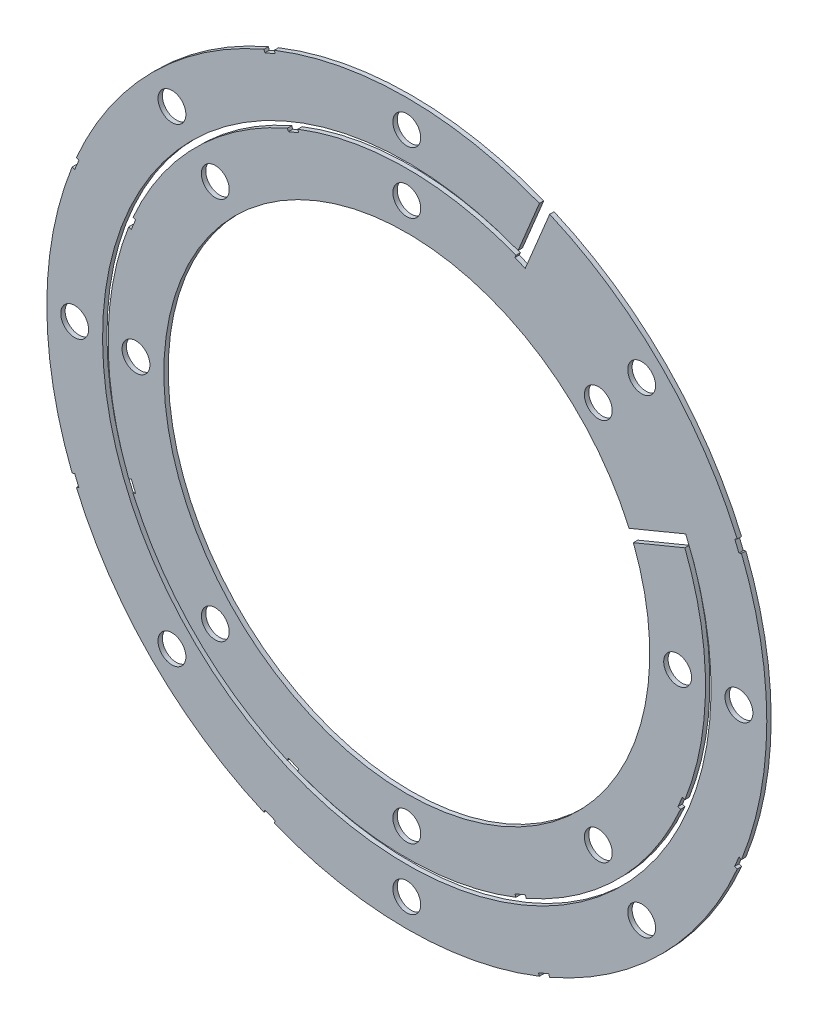
from build123d import *

# Parameters (mm, degrees)
BOSS_EXTRUDE1_DEPTH = 1
SKETCH2_R           = 3.17500001
SKETCH2_R_2         = 3.175
CUT_EXTRUDE1_DEPTH  = 2
CUT_EXTRUDE2_DEPTH  = 2


with BuildPart() as part:
    # Sketch1 → Boss-Extrude1 (new body)
    with BuildSketch(Plane.XY):
        with BuildLine():
            Line((25.358256565, 64.538916848), (30.219025255, 76.273850543))
            ThreePointArc((30.219025255, 76.273850543), (-31.396114158, -75.796924606), (32.565679267, 75.301834625))
            Line((32.565679267, 75.301834625), (27.218819563, 62.393373411))
            ThreePointArc((27.218819563, 62.393373411), (-49.023820587, -47.227769363), (63.365389329, 24.872165551))
            Line((63.365389329, 24.872165551), (51.629608078, 20.011045792))
            ThreePointArc((51.629608078, 20.011045792), (-51.157057474, -21.189947017), (50.65759216, 22.357699804))
            Line((50.65759216, 22.357699804), (63.56690093, 27.704910578))
            ThreePointArc((63.56690093, 27.704910578), (-48.125948441, -49.921999666), (25.358256565, 64.538916848))
        make_face()
    extrude(amount=BOSS_EXTRUDE1_DEPTH)

    # Sketch2 → Cut-Extrude1 (cut, through all)
    with BuildSketch(Plane.XY.offset(1)):
        with Locations((61.722, 0)):
            Circle(SKETCH2_R)
        with Locations((75.692, 0)):
            Circle(SKETCH2_R_2)
        with Locations((53.522326482, -53.522326482)):
            Circle(SKETCH2_R_2)
        with Locations((43.644044748, -43.644044748)):
            Circle(SKETCH2_R)
        with Locations((0, -75.692)):
            Circle(SKETCH2_R_2)
        with Locations((0, -61.722)):
            Circle(SKETCH2_R)
        with Locations((-53.522326482, -53.522326482)):
            Circle(SKETCH2_R_2)
        with Locations((-43.644044748, -43.644044748)):
            Circle(SKETCH2_R)
        with Locations((-75.692, 0)):
            Circle(SKETCH2_R_2)
        with Locations((-61.722, 0)):
            Circle(SKETCH2_R)
        with Locations((-53.522326482, 53.522326482)):
            Circle(SKETCH2_R_2)
        with Locations((-43.644044748, 43.644044748)):
            Circle(SKETCH2_R)
        with Locations((0, 75.692)):
            Circle(SKETCH2_R_2)
        with Locations((0, 61.722)):
            Circle(SKETCH2_R)
        with Locations((53.522326482, 53.522326482)):
            Circle(SKETCH2_R_2)
        with Locations((43.644044748, 43.644044748)):
            Circle(SKETCH2_R)
    extrude(amount=-CUT_EXTRUDE1_DEPTH, mode=Mode.SUBTRACT)

    # Sketch3 → Cut-Extrude2 (cut, through all)
    with BuildSketch(Plane.XY.offset(1)):
        Polygon((61.817656075, -26.980349635), (62.990983081, -27.466357594), (63.962998999, -25.119703581), (62.789671993, -24.633695622), align=None)
        Polygon((25.119703581, -63.962998999), (27.466357594, -62.990983081), (26.980349635, -61.817656075), (24.633695622, -62.789671993), align=None)
        Polygon((-27.466357594, -62.990983081), (-25.119703581, -63.962998999), (-24.633695622, -62.789671993), (-26.980349635, -61.817656075), align=None)
        Polygon((-63.962998999, -25.119703581), (-62.990983081, -27.466357594), (-61.817656075, -26.980349635), (-62.789671993, -24.633695622), align=None)
        Polygon((-62.990983081, 27.466357594), (-63.962998999, 25.119703581), (-62.789671993, 24.633695622), (-61.817656075, 26.980349635), align=None)
        Polygon((-25.119703581, 63.962998999), (-27.466357594, 62.990983081), (-26.980349635, 61.817656075), (-24.633695622, 62.789671993), align=None)
        Polygon((27.466357594, 62.990983081), (25.119703581, 63.962998999), (24.633695622, 62.789671993), (26.980349635, 61.817656075), align=None)
        Polygon((75.696269062, 29.979783172), (76.869596069, 30.465791131), (75.89758015, 32.812445144), (74.724253144, 32.326437185), align=None)
        Polygon((75.696269062, -29.979783172), (76.869596069, -30.465791131), (75.89758015, -32.812445144), (74.724253144, -32.326437185), align=None)
        Polygon((32.326437185, -74.724253144), (32.812445144, -75.89758015), (30.465791131, -76.869596069), (29.979783172, -75.696269062), align=None)
        Polygon((-29.979783172, -75.696269062), (-30.465791131, -76.869596069), (-32.812445144, -75.89758015), (-32.326437185, -74.724253144), align=None)
        Polygon((-74.724253144, -32.326437185), (-75.89758015, -32.812445144), (-76.869596069, -30.465791131), (-75.696269062, -29.979783172), align=None)
        Polygon((-75.696269062, 29.979783172), (-76.869596069, 30.465791131), (-75.89758015, 32.812445144), (-74.724253144, 32.326437185), align=None)
        Polygon((-32.326437185, 74.724253144), (-32.812445144, 75.89758015), (-30.465791131, 76.869596069), (-29.979783172, 75.696269062), align=None)
    extrude(amount=-CUT_EXTRUDE2_DEPTH, mode=Mode.SUBTRACT)


solid = part.part
